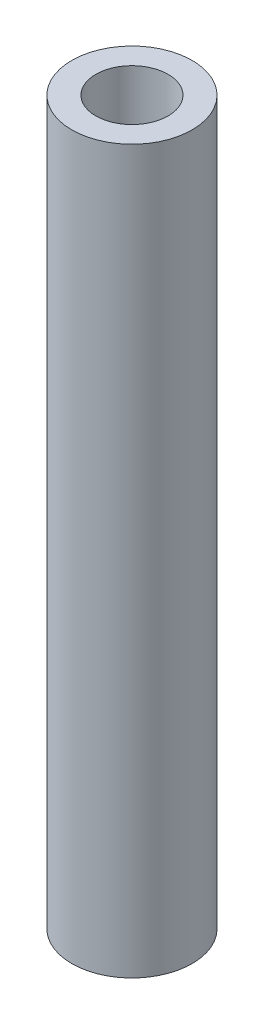
from build123d import *

# Parameters (mm, degrees)
SKETCH_1_R      = 2.5
SKETCH_1_R_2    = 1.5
EXTRUDE_1_DEPTH = 30


with BuildPart() as part:
    # 草图1 → 凸台-拉伸1 (new body)
    with BuildSketch(Plane(origin=(0, 0, 0), x_dir=(1, 0, 0), z_dir=(0, 1, 0))):
        Circle(SKETCH_1_R)
        Circle(SKETCH_1_R_2, mode=Mode.SUBTRACT)
    extrude(amount=EXTRUDE_1_DEPTH)


solid = part.part
